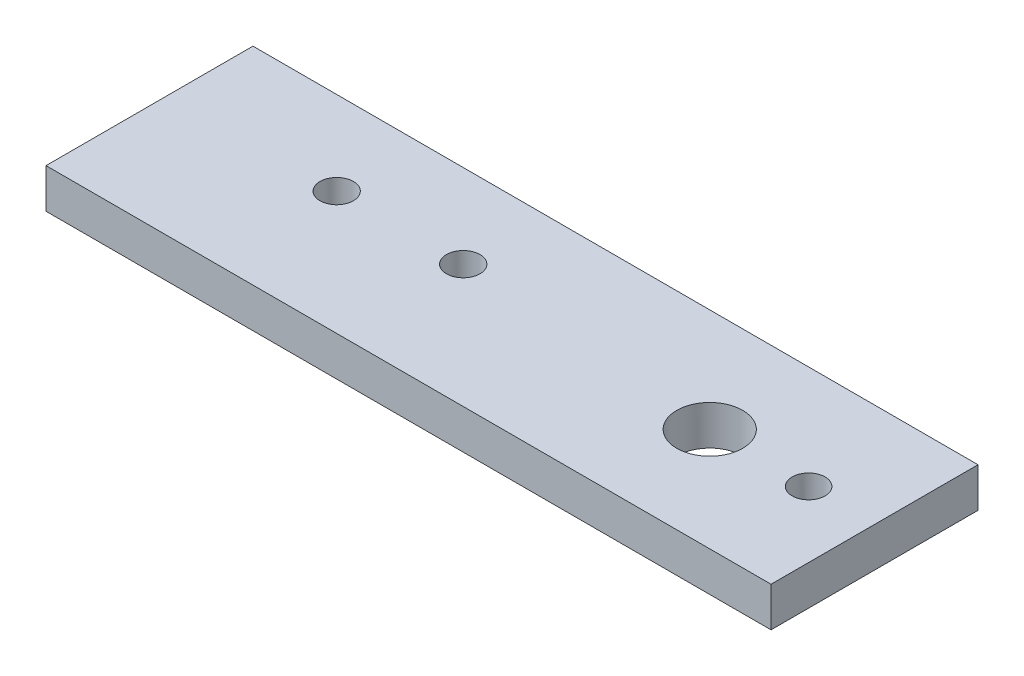
from build123d import *

# Parameters (mm, degrees)
SKETCH1_W               = 110
SKETCH1_H               = 31.4
BOSS_EXTRUDE1_DEPTH     = 6
SKETCH2_R               = 2.54
SKETCH2_R_2             = 5
SKETCH2_R_3             = 2.5
CUT_EXTRUDE1_DEPTH      = 1
CUT_EXTRUDE1_DEPTH_BACK = 7


with BuildPart() as part:
    # Sketch1 → Boss-Extrude1 (new body)
    with BuildSketch(Plane(origin=(0, 0, 0), x_dir=(1, 0, 0), z_dir=(0, 1, 0))):
        Rectangle(SKETCH1_W, SKETCH1_H)
    extrude(amount=BOSS_EXTRUDE1_DEPTH)

    # Sketch2 → Cut-Extrude1 (cut, two sides)
    with BuildSketch(Plane(origin=(0, 6, 0), x_dir=(1, 0, 0), z_dir=(0, 1, 0))) as cut_extrude1_sk:
        with Locations((-10.4, 3)):
            Circle(SKETCH2_R)
        with Locations((-29.6, 3)):
            Circle(SKETCH2_R)
        with Locations((30, 0)):
            Circle(SKETCH2_R_2)
        with Locations((45, 0)):
            Circle(SKETCH2_R_3)
    extrude(amount=CUT_EXTRUDE1_DEPTH, mode=Mode.SUBTRACT)
    extrude(cut_extrude1_sk.sketch, amount=-CUT_EXTRUDE1_DEPTH_BACK, mode=Mode.SUBTRACT)


solid = part.part
